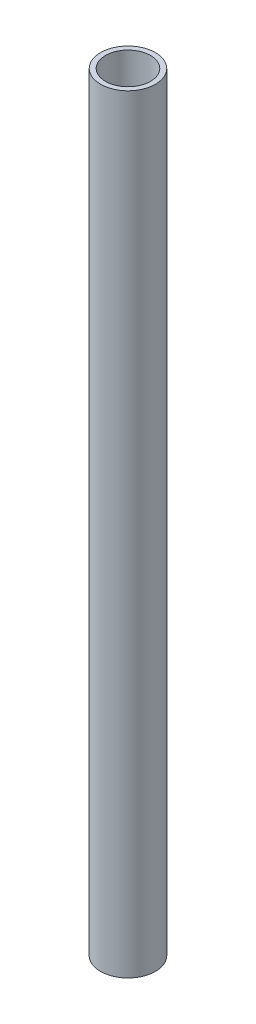
from build123d import *

# Parameters (mm, degrees)
SKETCH1_R           = 12.7
SKETCH1_R_2         = 10.414
BOSS_EXTRUDE1_DEPTH = 355.6


with BuildPart() as part:
    # Sketch1 → Boss-Extrude1 (new body)
    with BuildSketch(Plane(origin=(0, 0, 0), x_dir=(1, 0, 0), z_dir=(0, 1, 0))):
        Circle(SKETCH1_R)
        Circle(SKETCH1_R_2, mode=Mode.SUBTRACT)
    extrude(amount=BOSS_EXTRUDE1_DEPTH)


solid = part.part
